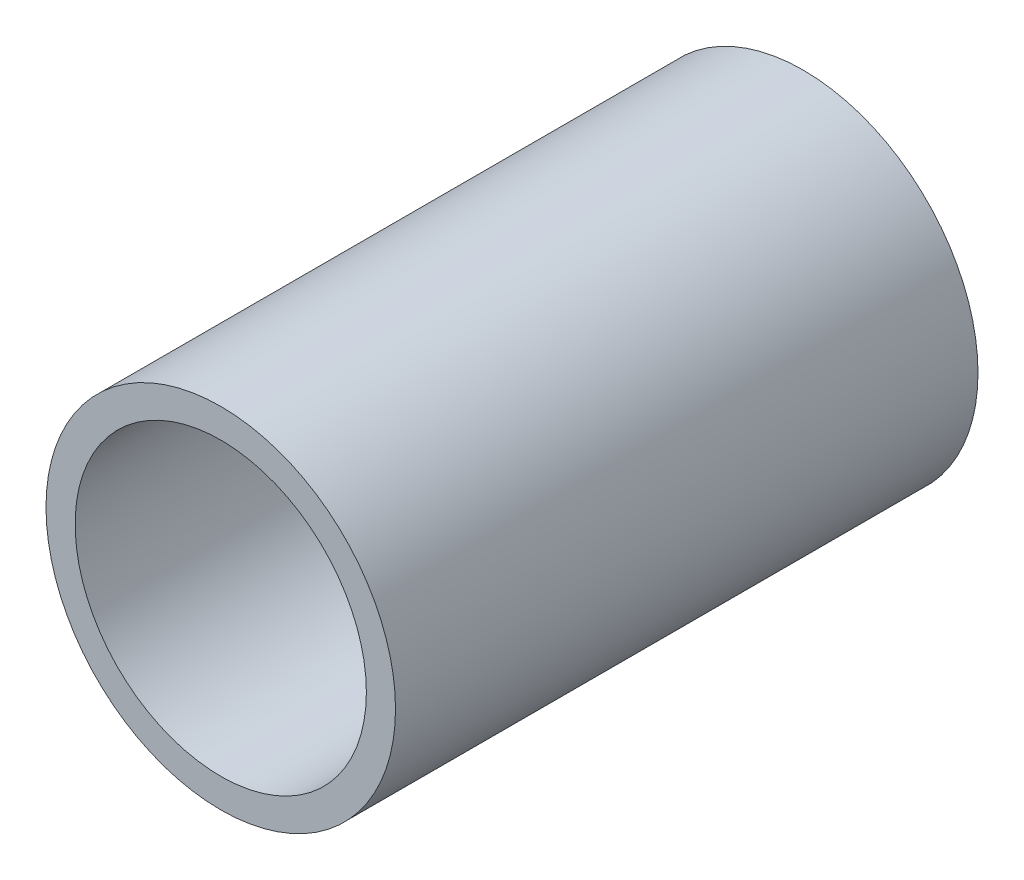
from build123d import *

# Parameters (mm, degrees)
SKETCH1_R           = 30
SKETCH1_R_2         = 25
BOSS_EXTRUDE1_DEPTH = 100


with BuildPart() as part:
    # Sketch1 → Boss-Extrude1 (new body)
    with BuildSketch(Plane.XY):
        Circle(SKETCH1_R)
        Circle(SKETCH1_R_2, mode=Mode.SUBTRACT)
    extrude(amount=BOSS_EXTRUDE1_DEPTH)


solid = part.part
